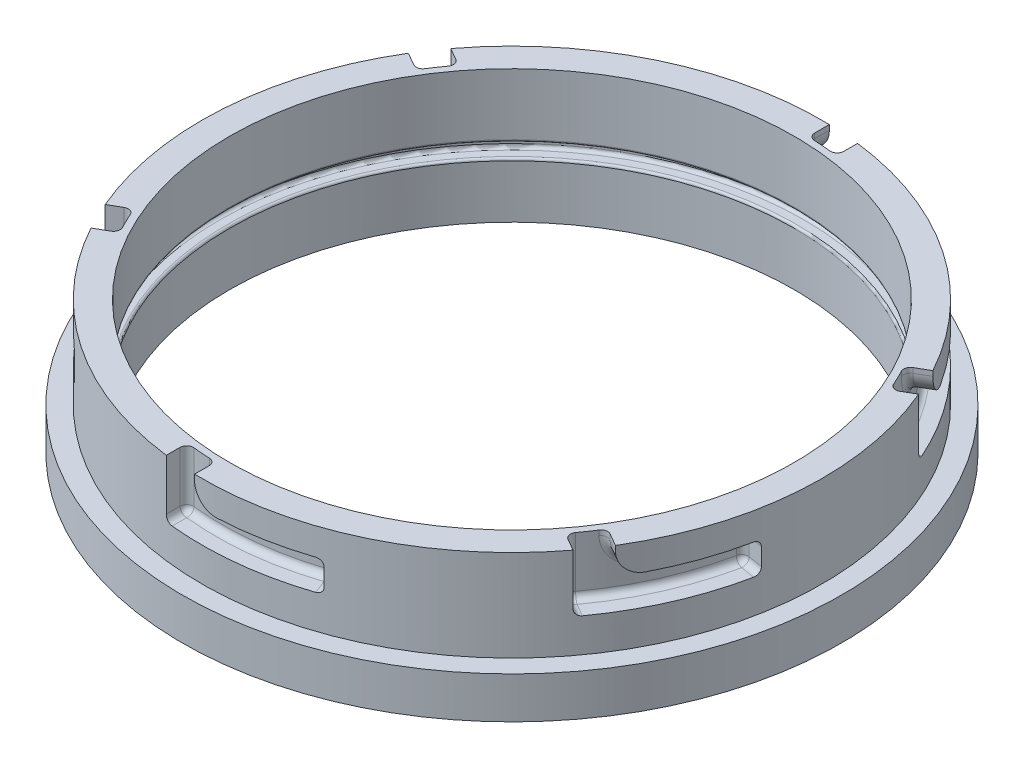
from build123d import *

# Parameters (mm, degrees)
CUT_EXTRUDE1_START       = -13.207999999999998
CUT_EXTRUDE1_DEPTH       = 13.207999999999998
SKETCH10_W               = 4.827435186195032
SKETCH10_H               = 6.984999999999999
FILLET1_R                = 5.08
FILLET7_R                = 1.524
CIRPATTERN1_COUNT        = 6
FILLET1_OF_CIRPATTERN1_R = 5.08
FILLET7_OF_CIRPATTERN1_R = 1.524
FILLET2_R                = 0.762
FILLET3_R                = 0.508


with BuildPart() as part:
    # Sketch1 → Revolve1 (revolve)
    with BuildSketch(Plane.XY):
        Polygon((71.11999999999999, 36.51250000000001), (71.11999999999999, 15.557500000000015), (75.56500000000001, 15.557500000000017), (75.565, 6.032500000000017), (64.77000000000001, 6.032500000000014), (64.77000000000001, 18.732500000000012), (67.81799999999998, 18.732500000000012), (67.81799999999998, 21.907500000000017), (64.77, 21.907500000000013), (64.77, 36.51250000000001), align=None)
    revolve(axis=Axis((0, 60.75795454545431, 0), (1.2e-16, -1, 0)))

    # Sketch2 → Cut-Extrude1 (cut)
    with BuildSketch(Plane(origin=(-4.47e-15, 36.5125, 0), x_dir=(1, 1.2e-16, 0), z_dir=(-1.2e-16, 1, 0)).offset(CUT_EXTRUDE1_START)):
        with BuildLine():
            Line((-8.659215820595662, -70.59088029889091), (-8.659215820595662, -65.7260406336206))
            ThreePointArc((-8.659215820595662, -65.7260406336206), (-5.173944735082208, -66.09179020028368), (-1.6742158205956637, -66.27285596219667))
            Line((-1.6742158205956637, -66.27285596219667), (-1.6742158205956637, -71.1002911483917))
            ThreePointArc((-1.6742158205956637, -71.1002911483917), (-5.172990162777308, -70.93161899164441), (-8.659215820595662, -70.59088029889091))
        make_face()
    cut_extrude1 = extrude(amount=CUT_EXTRUDE1_DEPTH, mode=Mode.SUBTRACT)

    # Cut-Sweep2: sweep along a path in Sketch23
    with BuildLine(Plane(origin=(-2.85e-15, 23.304500000000004, 0), x_dir=(1, 1.2e-16, 0), z_dir=(-1.2e-16, 1, 0))) as cut_sweep2_path:
        ThreePointArc((-1.6742158205956639, -71.1002911483917), (11.313422517678514, -70.21439219231685), (23.92201927626626, -66.97605089691348))
    # Sketch10 → Cut-Sweep2 (sweep, cut)
    with BuildSketch(Plane.ZY.offset(1.6742158205956639)):
        with Locations((68.68657355529419, 26.797000000000008)):
            Rectangle(SKETCH10_W, SKETCH10_H)
    cut_sweep2 = sweep(path=cut_sweep2_path.line, mode=Mode.SUBTRACT)

    # Fillet1
    fillet1_edges = [part.edges().sort_by_distance(p)[0] for p in [
        (-1.6742158205956676, 30.289500000000007, 68.68657355529419),
    ]]
    fillet(fillet1_edges, radius=FILLET1_R)

    # Fillet7
    fillet7_edges = [part.edges().sort_by_distance(p)[0] for p in [
        (-1.6742158205956668, 35.941, 66.27285596219667),
        (-0.18582286684972038, 31.776902176794007, 66.29373957046366),
        (23.05685308016756, 23.304500000000004, 64.72271557513899),
        (-8.659215820595666, 23.304500000000004, 68.15846046625575),
        (23.05685308016756, 30.289500000000007, 64.72271557513899),
        (22.191686884068872, 26.797000000000004, 62.46938025336449),
        (12.934414118168412, 30.289500000000007, 65.01996129974029),
        (6.95941107271422, 23.304500000000004, 65.92769549681668),
        (-8.659215820595668, 29.908500000000004, 65.7260406336206),
    ]]
    fillet(fillet7_edges, radius=FILLET7_R)

    # CirPattern1: Cut-Extrude1, Cut-Sweep2 ×6 about axis
    cirpattern1_axis = Axis((0, 60.75795454545431, 0), (-1.2e-16, 1, 0))
    add([cut_extrude1.rotate(cirpattern1_axis, i * 360 / CIRPATTERN1_COUNT) for i in range(1, CIRPATTERN1_COUNT)], mode=Mode.SUBTRACT)
    add([cut_sweep2.rotate(cirpattern1_axis, i * 360 / CIRPATTERN1_COUNT) for i in range(1, CIRPATTERN1_COUNT)], mode=Mode.SUBTRACT)

    # Fillet1 of CirPattern1
    fillet1_of_cirpattern1_edges = [part.edges().sort_by_distance(p)[0] for p in [
        (58.64720968749536, 30.289500000000015, 35.793200209700764),
        (60.321425508091046, 30.289500000000015, -32.89337334559342),
        (1.6742158205956834, 30.289500000000007, -68.68657355529419),
        (-58.647209687495334, 30.2895, -35.793200209700785),
        (-60.321425508091025, 30.2895, 32.89337334559344),
    ]]
    fillet(fillet1_of_cirpattern1_edges, radius=FILLET1_OF_CIRPATTERN1_R)

    # Fillet7 of CirPattern1
    fillet7_of_cirpattern1_edges = [part.edges().sort_by_distance(p)[0] for p in [
        (56.55686893431148, 35.94100000000001, 34.586341413152006),
        (57.31915114646635, 31.776902176794014, 33.30779710852775),
        (67.5799424300689, 23.30450000000001, 12.393537288818921),
        (54.697350336316994, 23.30450000000001, 41.57833111061584),
        (67.5799424300689, 30.289500000000015, 12.39353728881892),
        (65.19591370011806, 26.797000000000008, 12.016125532248683),
        (62.776145297740364, 30.289500000000015, 21.308449440468213),
        (60.574764649565296, 23.30450000000001, 26.936820964059127),
        (52.590812968585865, 29.90850000000001, 40.362121194298275),
        (58.23108475490716, 35.94100000000001, -31.68651454904466),
        (57.50497401331608, 31.776902176794014, -32.9859424619359),
        (44.52308934990136, 23.304500000000008, -52.329178286320065),
        (63.35656615691267, 23.30450000000001, -26.580129355639894),
        (44.52308934990136, 30.28950000000001, -52.329178286320065),
        (43.004226816049204, 26.797000000000008, -50.453254721115805),
        (49.841731179571966, 30.28950000000001, -43.71151185927207),
        (53.615353576851085, 23.30450000000001, -38.990874532757545),
        (61.25002878918154, 29.90850000000001, -25.36391943932232),
        (1.674215820595681, 35.941, -66.27285596219667),
        (0.1858228668497356, 31.776902176794007, -66.29373957046366),
        (-23.056853080167542, 23.304499999999997, -64.72271557513899),
        (8.659215820595682, 23.304500000000008, -68.15846046625575),
        (-23.056853080167546, 30.2895, -64.72271557513899),
        (-22.191686884068858, 26.796999999999997, -62.46938025336449),
        (-12.934414118168398, 30.289500000000004, -65.01996129974029),
        (-6.959411072714202, 23.304500000000004, -65.92769549681668),
        (8.659215820595682, 29.908500000000007, -65.7260406336206),
        (-56.55686893431146, 35.940999999999995, -34.58634141315203),
        (-57.319151146466325, 31.776902176794, -33.30779710852777),
        (-67.57994243006888, 23.304499999999994, -12.393537288818946),
        (-54.697350336316966, 23.304499999999997, -41.57833111061586),
        (-67.57994243006888, 30.289499999999997, -12.393537288818944),
        (-65.19591370011804, 26.796999999999993, -12.016125532248708),
        (-62.77614529774034, 30.289499999999997, -21.308449440468237),
        (-60.57476464956527, 23.304499999999997, -26.93682096405915),
        (-52.59081296858584, 29.908499999999997, -40.36212119429829),
        (-58.231084754907144, 35.940999999999995, 31.686514549044684),
        (-57.50497401331606, 31.776902176794, 32.98594246193592),
        (-44.52308934990133, 23.304499999999997, 52.32917828632009),
        (-63.356566156912656, 23.304499999999997, 26.580129355639915),
        (-44.52308934990133, 30.2895, 52.32917828632009),
        (-43.004226816049176, 26.796999999999997, 50.45325472111582),
        (-49.841731179571944, 30.2895, 43.711511859272086),
        (-53.615353576851064, 23.304499999999997, 38.990874532757566),
        (-61.25002878918153, 29.908499999999997, 25.36391943932234),
    ]]
    fillet(fillet7_of_cirpattern1_edges, radius=FILLET7_OF_CIRPATTERN1_R)

    # Fillet2
    fillet2_edges = [part.edges().sort_by_distance(p)[0] for p in [
        (-67.81799999999998, 21.9075, 8.31e-15),
        (-67.81799999999998, 18.7325, 8.31e-15),
    ]]
    fillet(fillet2_edges, radius=FILLET2_R)

    # Fillet3
    fillet3_edges = [part.edges().sort_by_distance(p)[0] for p in [
        (-64.77000000000001, 18.7325, 7.93e-15),
        (-64.77, 21.9075, 7.93e-15),
    ]]
    fillet(fillet3_edges, radius=FILLET3_R)


solid = part.part
